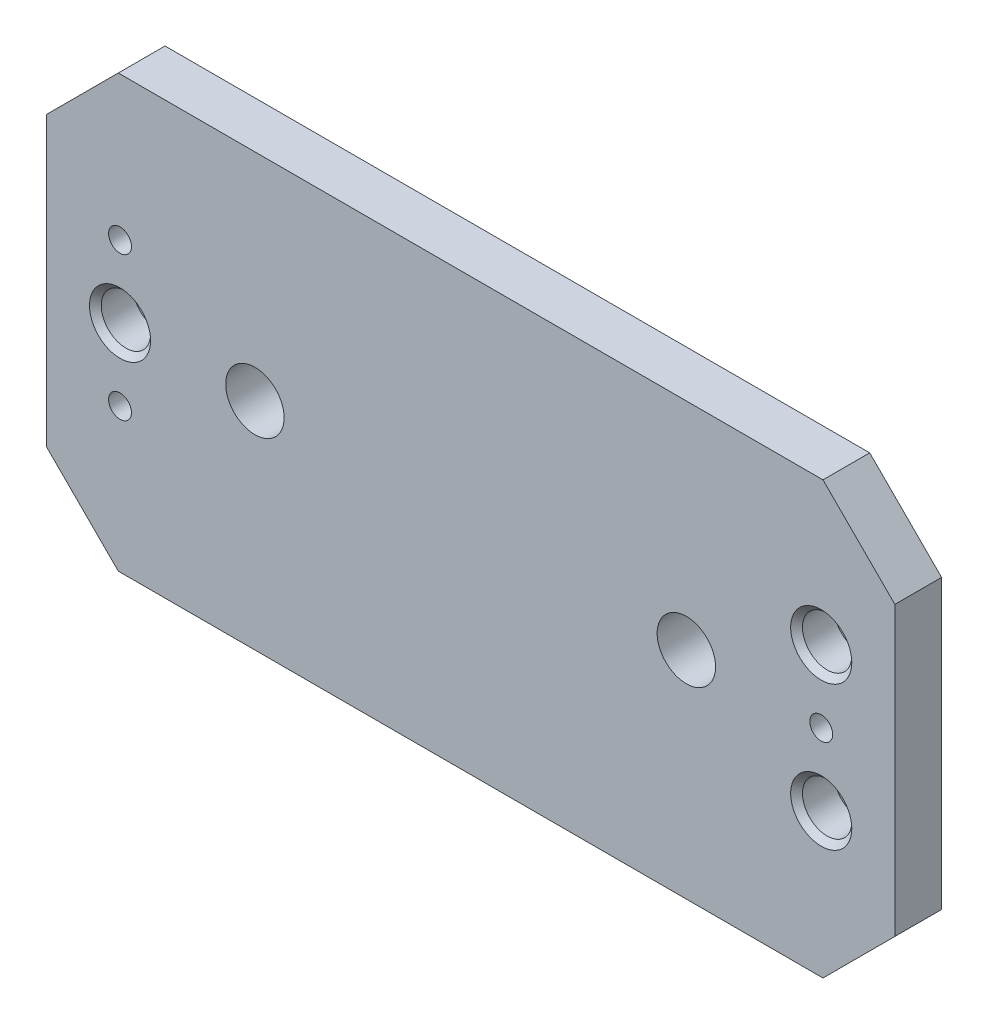
from build123d import *

# Parameters (mm, degrees)
SKETCH1_W                                    = 149.86
SKETCH1_H                                    = 76.2
EXTRUDE1_DEPTH                               = 9.017
SKETCH2_W                                    = 149.86
SKETCH2_H                                    = 76.2
SKETCH2_W_2                                  = 19.05
SKETCH2_H_2                                  = 38.1
CUT_EXTRUDE1_DEPTH                           = 0.762
F_10_32_TAPPED_HOLE1_D                       = 4.0386
CBORE_FOR_10_SOCKET_HEAD_CAP_SCREW1_AT_COUNT = 2
CBORE_FOR_10_SOCKET_HEAD_CAP_SCREW1_AT_PITCH = 124.499845703
CBORE_FOR_10_SOCKET_HEAD_CAP_SCREW1_2_COUNT  = 2
CBORE_FOR_10_SOCKET_HEAD_CAP_SCREW1_2_PITCH  = 25.4
CHAMFER1_SIZE                                = 12.7
SKETCH7_W                                    = 1.5748
SKETCH7_H                                    = 38.1
CUT_EXTRUDE2_DEPTH                           = 0.762
F_13_32_0_40625_DIAMETER_HOLE1_D             = 10.31875


with BuildPart() as part:
    # Sketch1 → Extrude1 (new body)
    with BuildSketch(Plane.XY):
        Rectangle(SKETCH1_W, SKETCH1_H)
    extrude(amount=EXTRUDE1_DEPTH)

    # Sketch2 → Cut-Extrude1 (cut)
    with BuildSketch(Plane(origin=(0, 0, 0), x_dir=(-1, 0, 0), z_dir=(0, 0, -1))):
        Rectangle(SKETCH2_W, SKETCH2_H)
        with Locations((-61.9252, 0)):
            Rectangle(SKETCH2_W_2, SKETCH2_H_2, mode=Mode.SUBTRACT)
        with Locations((61.9252, 0)):
            Rectangle(SKETCH2_W_2, SKETCH2_H_2, mode=Mode.SUBTRACT)
    extrude(amount=-CUT_EXTRUDE1_DEPTH, mode=Mode.SUBTRACT)

    # #10-32 Tapped Hole1 (through all)
    with Locations(Plane.XY.offset(9.017)):
        with Locations((61.9252, 0), (-61.9252, -12.7), (-61.9252, 12.7)):
            Hole(F_10_32_TAPPED_HOLE1_D / 2)

    # Sketch5 → CBORE for #10 Socket Head Cap Screw1 (revolve, cut)
    with BuildSketch(Plane(origin=(61.9252, -12.7, 9.017), x_dir=(0, -1, 0), z_dir=(1, 0, 0))):
        Polygon((0, 0), (0, 9.017), (2.8067, 9.017), (2.8067, 6.6548), (4.3561, 6.6548), (4.3561, 1.0414), (5.3975, 0), align=None)
    cbore_for_10_socket_head_cap_screw1 = revolve(axis=Axis((61.9252, -12.7, 15.367), (0, 0, -1)), mode=Mode.SUBTRACT)

    # CBORE for #10 Socket Head Cap Screw1 at: CBORE for #10 Socket Head Cap Screw1 ×2
    with Locations(*[Vector(-0.994783562, 0.102008159, 0) * (i * CBORE_FOR_10_SOCKET_HEAD_CAP_SCREW1_AT_PITCH) for i in range(1, CBORE_FOR_10_SOCKET_HEAD_CAP_SCREW1_AT_COUNT)]):
        add(cbore_for_10_socket_head_cap_screw1, mode=Mode.SUBTRACT)

    # CBORE for _10 Socket Head Cap Screw1 2: CBORE for #10 Socket Head Cap Screw1 ×2
    with Locations(*[(0, i * CBORE_FOR_10_SOCKET_HEAD_CAP_SCREW1_2_PITCH, 0) for i in range(1, CBORE_FOR_10_SOCKET_HEAD_CAP_SCREW1_2_COUNT)]):
        add(cbore_for_10_socket_head_cap_screw1, mode=Mode.SUBTRACT)

    # Chamfer1
    chamfer1_edges = [part.edges().sort_by_distance(p)[0] for p in [
        (74.93, -38.1, 4.8895),
        (-74.93, -38.1, 4.8895),
        (-74.93, 38.1, 4.8895),
        (74.93, 38.1, 4.8895),
    ]]
    chamfer(chamfer1_edges, length=CHAMFER1_SIZE)

    # Sketch7 → Cut-Extrude2 (cut)
    with BuildSketch(Plane(origin=(0, 0, 0), x_dir=(-1, 0, 0), z_dir=(0, 0, -1))):
        with Locations((61.9252, 0)):
            Rectangle(SKETCH7_W, SKETCH7_H)
        with Locations((-61.9252, 0)):
            Rectangle(SKETCH7_W, SKETCH7_H)
    extrude(amount=-CUT_EXTRUDE2_DEPTH, mode=Mode.SUBTRACT)

    # 13/32 (0.40625) Diameter Hole1 (through all)
    with Locations(Plane.XY.offset(9.017)):
        with Locations((38.1, 0), (-38.1, 0)):
            Hole(F_13_32_0_40625_DIAMETER_HOLE1_D / 2)


solid = part.part
